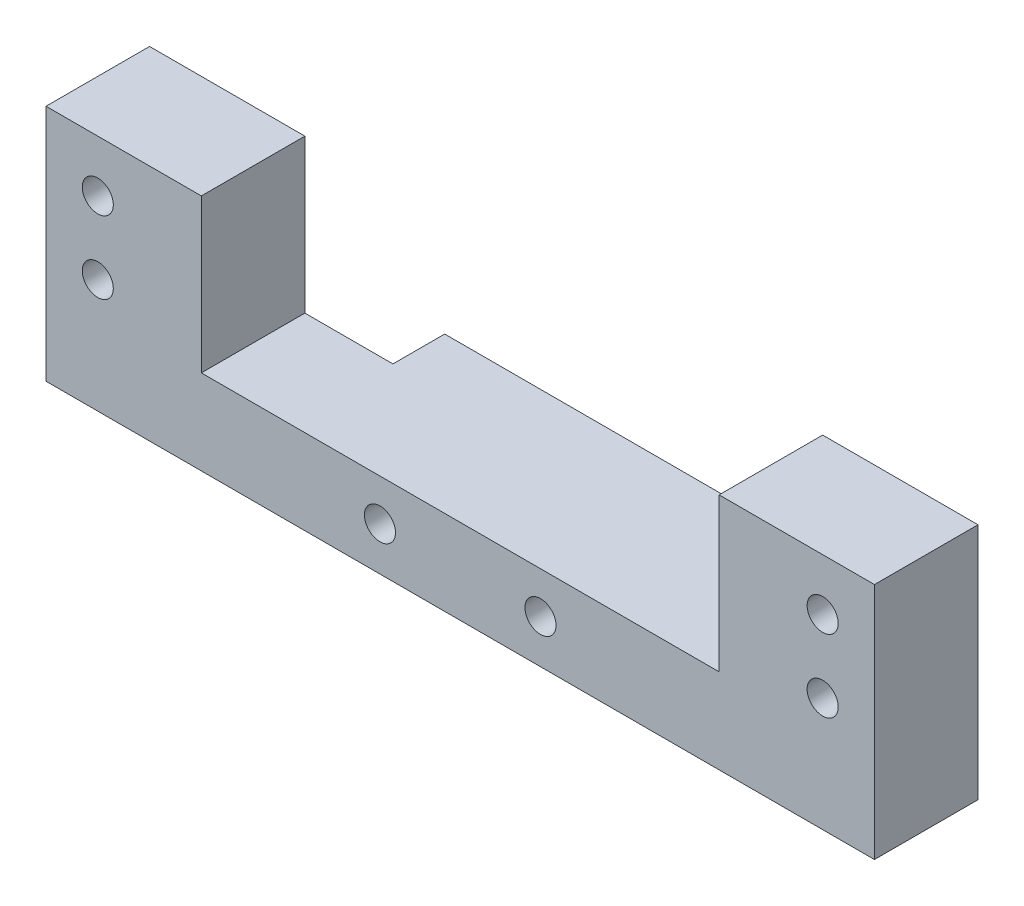
from build123d import *

# Parameters (mm, degrees)
SKETCH1_W           = 80
SKETCH1_H           = 23
BOSS_EXTRUDE3_DEPTH = 10
SKETCH4_W           = 50
SKETCH4_H           = 14.8
CUT_EXTRUDE1_DEPTH  = 10
SKETCH6_R           = 1.5
CUT_EXTRUDE5_DEPTH  = 10
SKETCH7_W           = 33
SKETCH7_H           = 8.2
BOSS_EXTRUDE4_DEPTH = 5
SKETCH5_R           = 1.5
CUT_EXTRUDE2_DEPTH  = 19


with BuildPart() as part:
    # Sketch1 → Boss-Extrude3 (new body)
    with BuildSketch(Plane.XY):
        with Locations((40, 11.5)):
            Rectangle(SKETCH1_W, SKETCH1_H)
    extrude(amount=BOSS_EXTRUDE3_DEPTH)

    # Sketch4 → Cut-Extrude1 (cut)
    with BuildSketch(Plane.XY.offset(10)):
        with Locations((40, 15.6)):
            Rectangle(SKETCH4_W, SKETCH4_H)
    extrude(amount=-CUT_EXTRUDE1_DEPTH, mode=Mode.SUBTRACT)

    # Sketch6 → Cut-Extrude5 (cut)
    with BuildSketch(Plane.XY.offset(10)):
        with Locations((5, 18)):
            Circle(SKETCH6_R)
        with Locations((5, 11)):
            Circle(SKETCH6_R)
        with Locations((75, 11)):
            Circle(SKETCH6_R)
        with Locations((75, 18)):
            Circle(SKETCH6_R)
    extrude(amount=-CUT_EXTRUDE5_DEPTH, mode=Mode.SUBTRACT)

    # Sketch7 → Boss-Extrude4 (add)
    with BuildSketch(Plane(origin=(0, 0, 0), x_dir=(-1, 0, 0), z_dir=(0, 0, -1))):
        with Locations((-40, 4.1)):
            Rectangle(SKETCH7_W, SKETCH7_H)
    extrude(amount=BOSS_EXTRUDE4_DEPTH)

    # Sketch5 → Cut-Extrude2 (cut)
    with BuildSketch(Plane.XY.offset(10)):
        with Locations((32.25, 4.2)):
            Circle(SKETCH5_R)
        with Locations((47.75, 4.2)):
            Circle(SKETCH5_R)
    extrude(amount=-CUT_EXTRUDE2_DEPTH, mode=Mode.SUBTRACT)


solid = part.part
